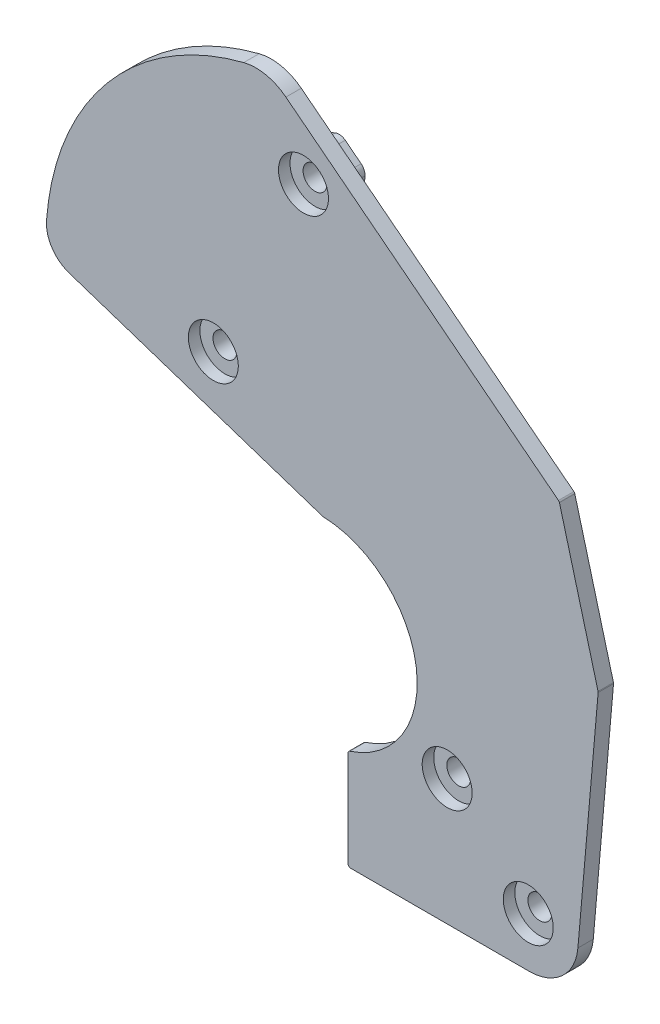
from build123d import *

# Parameters (mm, degrees)
Y_KSEKLIK_EKSTR_ZYON1_DEPTH = 2
Y_KSEKLIK_EKSTR_ZYON2_DEPTH = 3
IZIM5_R                     = 1.55
KES_EKSTR_ZYON1_DEPTH       = 5
IZIM6_R                     = 3.25
KES_EKSTR_ZYON2_DEPTH       = 1.5
KES_EKSTR_ZYON3_DEPTH       = 2


with BuildPart() as part:
    # Çizim1 → Yükseklik-Ekstrüzyon1 (new body)
    with BuildSketch(Plane.XY):
        with BuildLine():
            Line((-41.105081413, 11.299639377), (-8.113863068, 0.378628673))
            ThreePointArc((-8.113863068, 0.378628673), (4.01642262, -10.494132055), (-4.623817667, -24.303802743))
            ThreePointArc((-4.623817667, -24.303802743), (-4.799274482, -24.430880762), (-4.866322935, -24.63688664))
            Line((-4.866322935, -24.63688664), (-4.866322935, -37.083207178))
            ThreePointArc((-4.866322935, -37.083207178), (-4.763810308, -37.330694551), (-4.516322935, -37.433207178))
            Line((-4.516322935, -37.433207178), (18.719678074, -37.433207178))
            ThreePointArc((18.719678074, -37.433207178), (23.009675893, -35.764918267), (25.045514407, -31.636646144))
            Line((25.045514407, -31.636646144), (27.678537645, -1.541052822))
            ThreePointArc((27.678537645, -1.541052822), (27.678537645, -1.480043802), (27.66794354, -1.419961646))
            Line((27.66794354, -1.419961646), (22.642489235, 17.335289151))
            ThreePointArc((22.642489235, 17.335289151), (22.596275233, 17.43788043), (22.519896712, 17.520506249))
            Line((22.519896712, 17.520506249), (-12.9405872, 45.225272639))
            ThreePointArc((-12.9405872, 45.225272639), (-15.548952522, 46.436682119), (-18.424200647, 46.373193573))
            ThreePointArc((-18.424200647, 46.373193573), (-36.179435446, 35.192251208), (-44.076039074, 15.752459901))
            ThreePointArc((-44.076039074, 15.752459901), (-43.356576828, 13.014957214), (-41.105081413, 11.299639377))
        make_face()
    extrude(amount=-Y_KSEKLIK_EKSTR_ZYON1_DEPTH)

    # Çizim4 → Yükseklik-Ekstrüzyon2 (add)
    with BuildSketch(Plane(origin=(0, 0, -2), x_dir=(-1, 0, 0), z_dir=(0, 0, -1))):
        with BuildLine():
            Line((40.146596848, 14.195119879), (28.474092029, 10.331196191))
            Line((28.474092029, 10.331196191), (8.232284194, 3.630594906))
            ThreePointArc((8.232284194, 3.630594906), (7.642809613, 3.577387775), (7.090841177, 3.791027954))
            Line((7.090841177, 3.791027954), (5.755688832, 4.702398932))
            ThreePointArc((5.755688832, 4.702398932), (5.105662961, 4.970115176), (4.402900206, 4.951945686))
            ThreePointArc((4.402900206, 4.951945686), (4.10459824, 4.878061515), (3.807624001, 4.799009418))
            ThreePointArc((3.807624001, 4.799009418), (-6.360722696, -2.664063163), (-8.978039182, -15.002717113))
            ThreePointArc((-8.978039182, -15.002717113), (-8.865317675, -15.645084598), (-8.729007726, -16.282863339))
            ThreePointArc((-8.729007726, -16.282863339), (-8.359304972, -17.008921436), (-7.694222234, -17.479565078))
            Line((-7.694222234, -17.479565078), (-6.567842625, -17.921440305))
            ThreePointArc((-6.567842625, -17.921440305), (-6.142840412, -18.193337265), (-5.853364231, -18.606566472))
            ThreePointArc((-5.853364231, -18.606566472), (-3.610330722, -22.245790214), (-0.468752496, -25.145037533))
            Line((-0.468752496, -25.145037533), (-0.094474949, -25.398000973))
            ThreePointArc((-0.094474949, -25.398000973), (0.169709223, -25.567322514), (0.437224607, -25.73133038))
            Line((0.437224607, -25.73133038), (0.437224607, -34.383207178))
            Line((0.437224607, -34.383207178), (-5.021308607, -34.383207178))
            ThreePointArc((-5.021308607, -34.383207178), (-5.624718884, -33.868281437), (-6.396081315, -33.683207178))
            Line((-6.396081315, -33.683207178), (-6.780735729, -33.683207178))
            Line((-6.780735729, -33.683207178), (-14.98347518, -33.683207178))
            Line((-14.98347518, -33.683207178), (-18.719678074, -33.683207178))
            ThreePointArc((-18.719678074, -33.683207178), (-20.476212614, -33.000128254), (-21.309784289, -31.309812109))
            Line((-21.309784289, -31.309812109), (-21.406910581, -30.199653517))
            ThreePointArc((-21.406910581, -30.199653517), (-21.372380233, -29.76841651), (-21.198254298, -29.37238891))
            Line((-21.198254298, -29.37238891), (-20.618946502, -28.490888179))
            ThreePointArc((-20.618946502, -28.490888179), (-20.391243356, -27.973005932), (-20.346088286, -27.409080615))
            Line((-20.346088286, -27.409080615), (-20.37341709, -27.096710955))
            Line((-20.37341709, -27.096710955), (-22.555546966, -2.154852341))
            ThreePointArc((-22.555546966, -2.154852341), (-22.555546966, -1.92824741), (-22.516197432, -1.705085117))
            Line((-22.516197432, -1.705085117), (-18.284161659, 14.089087411))
            ThreePointArc((-18.284161659, 14.089087411), (-18.112509653, 14.470140733), (-17.828818002, 14.777036632))
            Line((-17.828818002, 14.777036632), (7.059291739, 34.221759043))
            ThreePointArc((7.059291739, 34.221759043), (7.388432983, 34.562743961), (7.61065263, 34.981340548))
            ThreePointArc((7.61065263, 34.981340548), (7.696032795, 35.32414247), (7.70871782, 35.677189239))
            Line((7.70871782, 35.677189239), (7.652642966, 36.498398251))
            ThreePointArc((7.652642966, 36.498398251), (7.762446578, 37.116689055), (8.149262911, 37.611374283))
            Line((8.149262911, 37.611374283), (10.2163345, 39.226347605))
            ThreePointArc((10.2163345, 39.226347605), (10.845026685, 39.490549235), (11.520958616, 39.400147972))
            Line((11.520958616, 39.400147972), (12.009191337, 39.194676987))
            ThreePointArc((12.009191337, 39.194676987), (12.893102324, 39.07645995), (13.715238257, 39.421954389))
            Line((13.715238257, 39.421954389), (16.049677651, 41.245818333))
            ThreePointArc((16.049677651, 41.245818333), (16.583673701, 41.493823423), (17.172307175, 41.480825768))
            ThreePointArc((17.172307175, 41.480825768), (18.108862659, 41.224498821), (19.036372112, 40.937156005))
            ThreePointArc((19.036372112, 40.937156005), (19.943021213, 40.894666775), (20.742308561, 41.32473382))
            Line((20.742308561, 41.32473382), (20.971778793, 41.544527828))
            ThreePointArc((20.971778793, 41.544527828), (21.642700826, 41.88550301), (22.390140455, 41.797557284))
            ThreePointArc((22.390140455, 41.797557284), (35.367714895, 31.255849206), (41.034469252, 15.525847852))
            ThreePointArc((41.034469252, 15.525847852), (40.819457547, 14.7077436), (40.146596848, 14.195119879))
        make_face()
    extrude(amount=Y_KSEKLIK_EKSTR_ZYON2_DEPTH)

    # Çizim5 → Kes-Ekstrüzyon1 (cut)
    with BuildSketch(Plane.XY):
        with Locations((18.588315087, -30.988106158)):
            Circle(IZIM5_R)
        with Locations((8.040668379, -21.065272587)):
            Circle(IZIM5_R)
        with Locations((-22.376194422, 11.828332979)):
            Circle(IZIM5_R)
        with Locations((-10.655916137, 36.555534849)):
            Circle(IZIM5_R)
    extrude(amount=-KES_EKSTR_ZYON1_DEPTH, mode=Mode.SUBTRACT)

    # Çizim6 → Kes-Ekstrüzyon2 (cut)
    with BuildSketch(Plane.XY):
        with Locations((18.588315087, -30.988106158)):
            Circle(IZIM6_R)
        with Locations((8.040668379, -21.065272587)):
            Circle(IZIM6_R)
        with Locations((-22.376194422, 11.828332979)):
            Circle(IZIM6_R)
        with Locations((-10.655916137, 36.555534849)):
            Circle(IZIM6_R)
    extrude(amount=-KES_EKSTR_ZYON2_DEPTH, mode=Mode.SUBTRACT)

    # Çizim7 → Kes-Ekstrüzyon3 (cut)
    with BuildSketch(Plane(origin=(0, 0, -5), x_dir=(-1, 0, 0), z_dir=(0, 0, -1))):
        with BuildLine():
            Line((24.541267724, 38.1096017), (23.517717526, 39.20403478))
            ThreePointArc((23.517717526, 39.20403478), (21.655481578, 40.136777833), (19.634741325, 39.632257115))
            Line((19.634741325, 39.632257115), (16.611199337, 37.567393667))
            ThreePointArc((16.611199337, 37.567393667), (16.488455807, 37.476506841), (16.373005674, 37.376518561))
            Line((16.373005674, 37.376518561), (11.637268483, 32.947499711))
            ThreePointArc((11.637268483, 32.947499711), (11.004872743, 31.563837931), (11.528839766, 30.135586253))
            Line((11.528839766, 30.135586253), (14.814792499, 26.549635137))
            Line((14.814792499, 26.549635137), (27.066921229, 13.449022186))
            ThreePointArc((27.066921229, 13.449022186), (27.732524284, 12.979727648), (28.529940113, 12.814219991))
            Line((28.529940113, 12.814219991), (33.452123381, 12.814639194))
            ThreePointArc((33.452123381, 12.814639194), (34.638107313, 13.059129065), (35.630822107, 13.752562927))
            Line((35.630822107, 13.752562927), (38.266714728, 16.537857285))
            ThreePointArc((38.266714728, 16.537857285), (38.901592885, 17.559574312), (39.084076841, 18.748555205))
            Line((39.084076841, 18.748555205), (38.920753656, 22.041264477))
            ThreePointArc((38.920753656, 22.041264477), (38.764745082, 22.722405414), (38.383934887, 23.308302374))
            Line((38.383934887, 23.308302374), (24.541267724, 38.1096017))
        make_face()
    extrude(amount=-KES_EKSTR_ZYON3_DEPTH, mode=Mode.SUBTRACT)


solid = part.part
